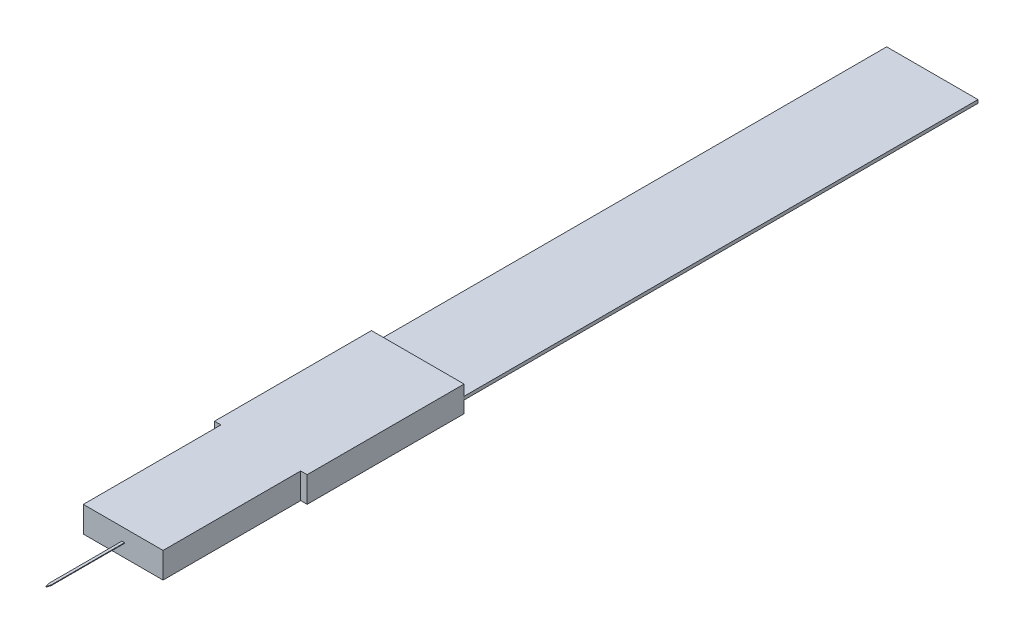
from build123d import *

# Parameters (mm, degrees)
SKETCH1_W           = 6.2
SKETCH1_H           = 10.7
BOSS_EXTRUDE1_DEPTH = 2
SKETCH2_W           = 7.1
SKETCH2_H           = 0.25368462
BOSS_EXTRUDE2_DEPTH = 40
SKETCH3_W           = 0.2
SKETCH3_H           = 0.05
BOSS_EXTRUDE3_DEPTH = 6
CUT_EXTRUDE1_DEPTH  = 0.05


with BuildPart() as part:
    # Sketch1 → Boss-Extrude1 (new body)
    with BuildSketch(Plane(origin=(0, 0, 0), x_dir=(1, 0, 0), z_dir=(0, 1, 0))):
        Polygon((-3.6, -6.1), (-3.1, -6.1), (3.1, -6.1), (3.6, -6.1), (3.6, 6.1), (-3.6, 6.1), align=None)
        with Locations((0, -11.45)):
            Rectangle(SKETCH1_W, SKETCH1_H)
    extrude(amount=BOSS_EXTRUDE1_DEPTH)

    # Sketch2 → Boss-Extrude2 (add)
    with BuildSketch(Plane(origin=(0, 0, -6.1), x_dir=(-1, 0, 0), z_dir=(0, 0, -1))):
        with Locations((0, 1)):
            Rectangle(SKETCH2_W, SKETCH2_H)
    extrude(amount=BOSS_EXTRUDE2_DEPTH)

    # Sketch3 → Boss-Extrude3 (add)
    with BuildSketch(Plane.XY.offset(16.8)):
        with Locations((0, 1)):
            Rectangle(SKETCH3_W, SKETCH3_H)
    extrude(amount=BOSS_EXTRUDE3_DEPTH)

    # Sketch4 → Cut-Extrude1 (cut)
    with BuildSketch(Plane.XZ.offset(-0.975)):
        Polygon((0.1, 22.8), (0, 22.8), (0.1, 22.5), align=None)
        Polygon((-0.1, 22.8), (-0.1, 22.5), (0, 22.8), align=None)
    extrude(amount=-CUT_EXTRUDE1_DEPTH, mode=Mode.SUBTRACT)


solid = part.part
